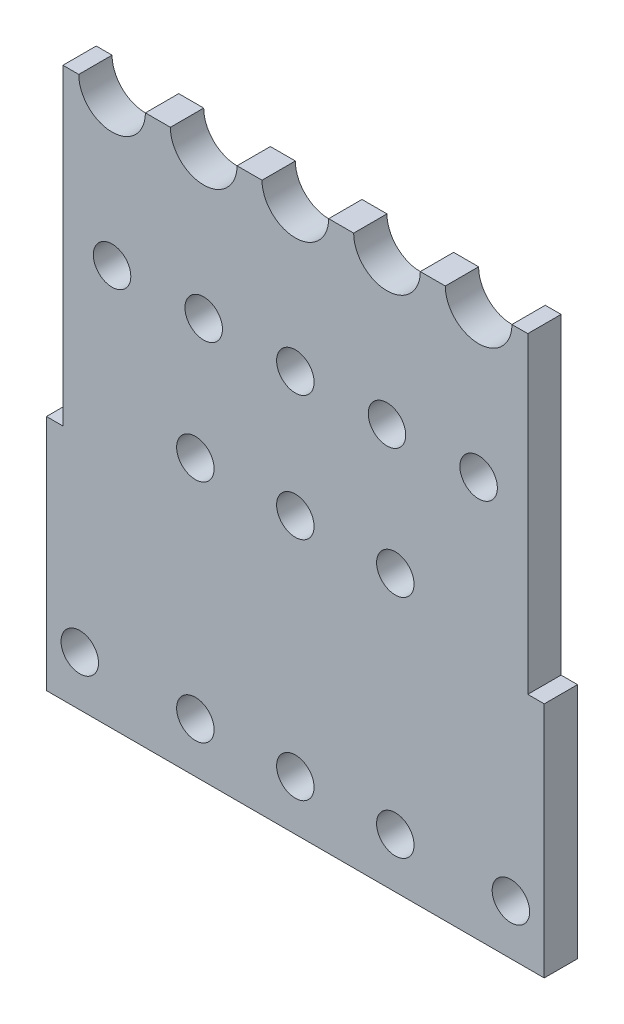
from build123d import *

# Parameters (mm, degrees)
SKETCH_1_W          = 11.95
SKETCH_1_H          = 13.2
EXTRUDE_1_DEPTH     = 0.8
SKETCH_2_W          = 0.395
SKETCH_2_H          = 7.5
CUT_EXTRUDE_1_DEPTH = 0.8
CUT_EXTRUDE_2_DEPTH = 0.8
SKETCH_4_R          = 0.45
CUT_EXTRUDE_3_DEPTH = 0.8


with BuildPart() as part:
    # Эскиз1 → Бобышка-Вытянуть1 (new body)
    with BuildSketch(Plane.XY):
        Rectangle(SKETCH_1_W, SKETCH_1_H)
    extrude(amount=EXTRUDE_1_DEPTH)

    # Эскиз2 → Вырез-Вытянуть1 (cut)
    with BuildSketch(Plane.XY.offset(0.8)):
        with Locations((-5.7775, 2.85)):
            Rectangle(SKETCH_2_W, SKETCH_2_H)
        with Locations((5.7775, 2.85)):
            Rectangle(SKETCH_2_W, SKETCH_2_H)
    extrude(amount=-CUT_EXTRUDE_1_DEPTH, mode=Mode.SUBTRACT)

    # Эскиз3 → Вырез-Вытянуть2 (cut)
    with BuildSketch(Plane.XY.offset(0.8)):
        with BuildLine():
            Line((-5.2, 6.6), (-3.6, 6.6))
            ThreePointArc((-3.6, 6.6), (-4.4, 5.8), (-5.2, 6.6))
        make_face()
        with BuildLine():
            Line((-3, 6.6), (-1.4, 6.6))
            ThreePointArc((-1.4, 6.6), (-2.2, 5.8), (-3, 6.6))
        make_face()
        with BuildLine():
            Line((-0.8, 6.6), (0.8, 6.6))
            ThreePointArc((0.8, 6.6), (0, 5.8), (-0.8, 6.6))
        make_face()
        with BuildLine():
            Line((1.4, 6.6), (3, 6.6))
            ThreePointArc((3, 6.6), (2.2, 5.8), (1.4, 6.6))
        make_face()
        with BuildLine():
            Line((3.6, 6.6), (5.2, 6.6))
            ThreePointArc((5.2, 6.6), (4.4, 5.8), (3.6, 6.6))
        make_face()
    extrude(amount=-CUT_EXTRUDE_2_DEPTH, mode=Mode.SUBTRACT)

    # Эскиз4 → Вырез-Вытянуть3 (cut)
    with BuildSketch(Plane.XY.offset(0.8)):
        with Locations((-2.4, -5.4)):
            Circle(SKETCH_4_R)
        with Locations((0, -5.4)):
            Circle(SKETCH_4_R)
        with Locations((2.4, -5.4)):
            Circle(SKETCH_4_R)
        with Locations((-2.4, 0.025)):
            Circle(SKETCH_4_R)
        with Locations((0, 0.025)):
            Circle(SKETCH_4_R)
        with Locations((2.4, 0.025)):
            Circle(SKETCH_4_R)
        with Locations((-5.175, -5.4)):
            Circle(SKETCH_4_R)
        with Locations((5.175, -5.4)):
            Circle(SKETCH_4_R)
        with Locations((-4.4, 3.025)):
            Circle(SKETCH_4_R)
        with Locations((-2.2, 3.025)):
            Circle(SKETCH_4_R)
        with Locations((0, 3.025)):
            Circle(SKETCH_4_R)
        with Locations((2.2, 3.025)):
            Circle(SKETCH_4_R)
        with Locations((4.4, 3.025)):
            Circle(SKETCH_4_R)
    extrude(amount=-CUT_EXTRUDE_3_DEPTH, mode=Mode.SUBTRACT)


solid = part.part
